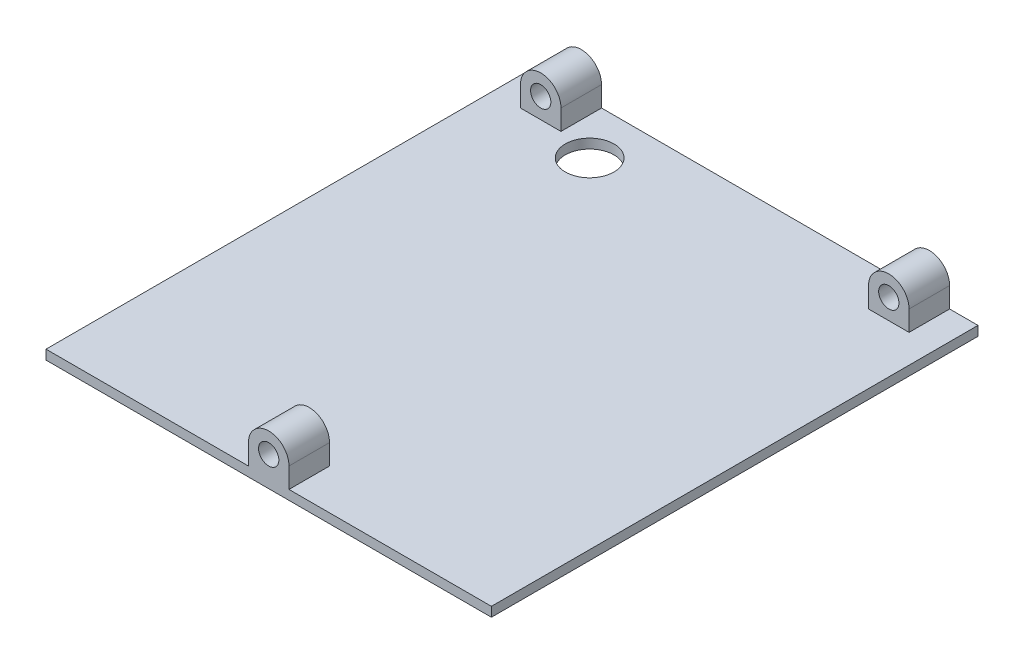
from build123d import *

# Parameters (mm, degrees)
SKETCH1_W           = 139.5
SKETCH1_H           = 152.4
BOSS_EXTRUDE1_DEPTH = 6.35
SKETCH2_W           = 139.5
SKETCH2_H           = 152.4
CUT_EXTRUDE1_DEPTH  = 3.375
SKETCH3_R           = 3.175
BOSS_EXTRUDE2_DEPTH = 12.7
SKETCH4_R           = 3.175000001
SKETCH4_R_2         = 3.175
BOSS_EXTRUDE3_DEPTH = 12.7
SKETCH5_R           = 7.62
CUT_EXTRUDE2_DEPTH  = 16.675000317


with BuildPart() as part:
    # Sketch1 → Boss-Extrude1 (new body)
    with BuildSketch(Plane(origin=(0, 0, 0), x_dir=(1, 0, 0), z_dir=(0, 1, 0))):
        with Locations((69.75, 76.2)):
            Rectangle(SKETCH1_W, SKETCH1_H)
    extrude(amount=BOSS_EXTRUDE1_DEPTH)

    # Sketch2 → Cut-Extrude1 (cut)
    with BuildSketch(Plane(origin=(0, 6.35, 0), x_dir=(1, 0, 0), z_dir=(0, 1, 0))):
        with Locations((69.75, 76.2)):
            Rectangle(SKETCH2_W, SKETCH2_H)
    extrude(amount=-CUT_EXTRUDE1_DEPTH, mode=Mode.SUBTRACT)

    # Sketch3 → Boss-Extrude2 (add)
    with BuildSketch(Plane.XY):
        with BuildLine():
            Line((63.4, 9.325), (63.4, 2.975))
            Line((63.4, 2.975), (76.1, 2.975))
            Line((76.1, 2.975), (76.1, 9.325000633))
            ThreePointArc((76.1, 9.325000633), (69.749999683, 15.675000317), (63.4, 9.325))
        make_face()
        with Locations((69.75, 9.325000317)):
            Circle(SKETCH3_R, mode=Mode.SUBTRACT)
    extrude(amount=-BOSS_EXTRUDE2_DEPTH)

    # Sketch4 → Boss-Extrude3 (add)
    with BuildSketch(Plane(origin=(0, 0, -152.4), x_dir=(-1, 0, 0), z_dir=(0, 0, -1))):
        with BuildLine():
            Line((-130.61, 9.325), (-130.61, 2.975))
            Line((-130.61, 2.975), (-117.91, 2.975))
            Line((-117.91, 2.975), (-117.91, 9.325))
            ThreePointArc((-117.91, 9.325), (-124.26, 15.675), (-130.61, 9.325))
        make_face()
        with Locations((-124.26, 9.325)):
            Circle(SKETCH4_R, mode=Mode.SUBTRACT)
        with BuildLine():
            Line((-21.59, 9.325), (-21.59, 2.975))
            Line((-21.59, 2.975), (-8.89, 2.975))
            Line((-8.89, 2.975), (-8.89, 9.325))
            ThreePointArc((-8.89, 9.325), (-15.24, 15.675), (-21.59, 9.325))
        make_face()
        with Locations((-15.24, 9.325)):
            Circle(SKETCH4_R_2, mode=Mode.SUBTRACT)
    extrude(amount=-BOSS_EXTRUDE3_DEPTH)

    # Sketch5 → Cut-Extrude2 (cut, through all)
    with BuildSketch(Plane.XZ):
        with Locations((33.274, -136.991598)):
            Circle(SKETCH5_R)
    extrude(amount=-CUT_EXTRUDE2_DEPTH, mode=Mode.SUBTRACT)


solid = part.part
